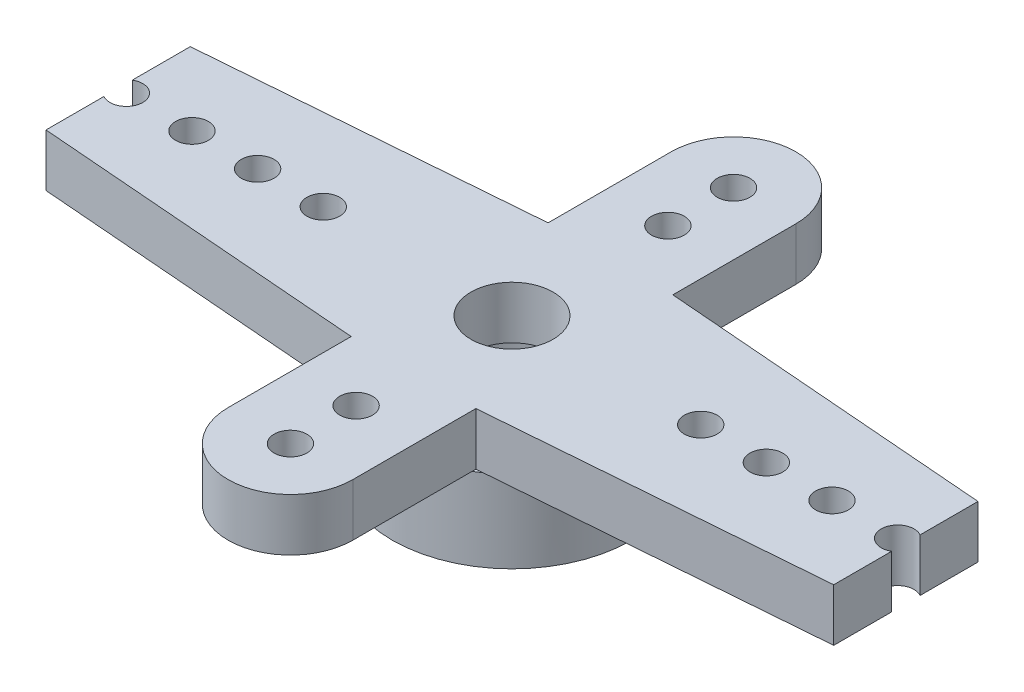
from build123d import *

# Parameters (mm, degrees)
SKETCH1_R           = 3.65
SKETCH1_R_2         = 2.5
BOSS_EXTRUDE1_DEPTH = 2.5
SKETCH2_R           = 1.25
BOSS_EXTRUDE2_DEPTH = 1.6
CUT_EXTRUDE1_REACH  = 6.1
SKETCH3_R           = 0.5
SKETCH4_W           = 8.285333373
SKETCH4_H           = 11.992925475
CUT_EXTRUDE2_DEPTH  = 5.1


with BuildPart() as part:
    # Sketch1 → Boss-Extrude1 (new body)
    with BuildSketch(Plane(origin=(0, 0, 0), x_dir=(1, 0, 0), z_dir=(0, 1, 0))):
        Circle(SKETCH1_R)
        Circle(SKETCH1_R_2, mode=Mode.SUBTRACT)
    extrude(amount=BOSS_EXTRUDE1_DEPTH)

    # Sketch2 → Boss-Extrude2 (add)
    with BuildSketch(Plane(origin=(0, 2.5, 0), x_dir=(1, 0, 0), z_dir=(0, 1, 0))):
        with BuildLine():
            Line((-1.9, 6.75), (-1.9, 3))
            Line((-1.9, 3), (-15.75, 1.9))
            ThreePointArc((-15.75, 1.9), (-17.65, 0), (-15.75, -1.9))
            Line((-15.75, -1.9), (-1.9, -3))
            Line((-1.9, -3), (-1.9, -6.75))
            ThreePointArc((-1.9, -6.75), (0, -8.65), (1.9, -6.75))
            Line((1.9, -6.75), (1.9, -3))
            Line((1.9, -3), (15.75, -1.9))
            ThreePointArc((15.75, -1.9), (17.65, 0), (15.75, 1.9))
            Line((15.75, 1.9), (1.9, 3))
            Line((1.9, 3), (1.9, 6.75))
            ThreePointArc((1.9, 6.75), (0, 8.65), (-1.9, 6.75))
        make_face()
        Circle(SKETCH2_R, mode=Mode.SUBTRACT)
    extrude(amount=BOSS_EXTRUDE2_DEPTH)

    # Sketch3 → Cut-Extrude1 (cut, up to next)
    with BuildSketch(Plane(origin=(0, 4.1, 0), x_dir=(1, 0, 0), z_dir=(0, 1, 0)), mode=Mode.PRIVATE) as cut_extrude1_sk1:
        with Locations((0, 6.75)):
            Circle(SKETCH3_R)
    cut_extrude1_tool1 = extrude(cut_extrude1_sk1.sketch, amount=-CUT_EXTRUDE1_REACH, mode=Mode.PRIVATE) & part.part
    add(cut_extrude1_tool1.solids().sort_by_distance((0, 4.1, -6.75))[0], mode=Mode.SUBTRACT)
    # Sketch3 → Cut-Extrude1 (cut, up to next)
    with BuildSketch(Plane(origin=(0, 4.1, 0), x_dir=(1, 0, 0), z_dir=(0, 1, 0)), mode=Mode.PRIVATE) as cut_extrude1_sk2:
        with Locations((0, 4.75)):
            Circle(SKETCH3_R)
    cut_extrude1_tool2 = extrude(cut_extrude1_sk2.sketch, amount=-CUT_EXTRUDE1_REACH, mode=Mode.PRIVATE) & part.part
    add(cut_extrude1_tool2.solids().sort_by_distance((0, 4.1, -4.75))[0], mode=Mode.SUBTRACT)
    # Sketch3 → Cut-Extrude1 (cut, up to next)
    with BuildSketch(Plane(origin=(0, 4.1, 0), x_dir=(1, 0, 0), z_dir=(0, 1, 0)), mode=Mode.PRIVATE) as cut_extrude1_sk3:
        with Locations((-15.75, 0)):
            Circle(SKETCH3_R)
    cut_extrude1_tool3 = extrude(cut_extrude1_sk3.sketch, amount=-CUT_EXTRUDE1_REACH, mode=Mode.PRIVATE) & part.part
    add(cut_extrude1_tool3.solids().sort_by_distance((-15.75, 4.1, 0))[0], mode=Mode.SUBTRACT)
    # Sketch3 → Cut-Extrude1 (cut, up to next)
    with BuildSketch(Plane(origin=(0, 4.1, 0), x_dir=(1, 0, 0), z_dir=(0, 1, 0)), mode=Mode.PRIVATE) as cut_extrude1_sk4:
        with Locations((-13.75, 0)):
            Circle(SKETCH3_R)
    cut_extrude1_tool4 = extrude(cut_extrude1_sk4.sketch, amount=-CUT_EXTRUDE1_REACH, mode=Mode.PRIVATE) & part.part
    add(cut_extrude1_tool4.solids().sort_by_distance((-13.75, 4.1, 0))[0], mode=Mode.SUBTRACT)
    # Sketch3 → Cut-Extrude1 (cut, up to next)
    with BuildSketch(Plane(origin=(0, 4.1, 0), x_dir=(1, 0, 0), z_dir=(0, 1, 0)), mode=Mode.PRIVATE) as cut_extrude1_sk5:
        with Locations((-11.75, 0)):
            Circle(SKETCH3_R)
    cut_extrude1_tool5 = extrude(cut_extrude1_sk5.sketch, amount=-CUT_EXTRUDE1_REACH, mode=Mode.PRIVATE) & part.part
    add(cut_extrude1_tool5.solids().sort_by_distance((-11.75, 4.1, 0))[0], mode=Mode.SUBTRACT)
    # Sketch3 → Cut-Extrude1 (cut, up to next)
    with BuildSketch(Plane(origin=(0, 4.1, 0), x_dir=(1, 0, 0), z_dir=(0, 1, 0)), mode=Mode.PRIVATE) as cut_extrude1_sk6:
        with Locations((-9.75, 0)):
            Circle(SKETCH3_R)
    cut_extrude1_tool6 = extrude(cut_extrude1_sk6.sketch, amount=-CUT_EXTRUDE1_REACH, mode=Mode.PRIVATE) & part.part
    add(cut_extrude1_tool6.solids().sort_by_distance((-9.75, 4.1, 0))[0], mode=Mode.SUBTRACT)
    # Sketch3 → Cut-Extrude1 (cut, up to next)
    with BuildSketch(Plane(origin=(0, 4.1, 0), x_dir=(1, 0, 0), z_dir=(0, 1, 0)), mode=Mode.PRIVATE) as cut_extrude1_sk7:
        with Locations((-7.75, 0)):
            Circle(SKETCH3_R)
    cut_extrude1_tool7 = extrude(cut_extrude1_sk7.sketch, amount=-CUT_EXTRUDE1_REACH, mode=Mode.PRIVATE) & part.part
    add(cut_extrude1_tool7.solids().sort_by_distance((-7.75, 4.1, 0))[0], mode=Mode.SUBTRACT)
    # Sketch3 → Cut-Extrude1 (cut, up to next)
    with BuildSketch(Plane(origin=(0, 4.1, 0), x_dir=(1, 0, 0), z_dir=(0, 1, 0)), mode=Mode.PRIVATE) as cut_extrude1_sk8:
        with Locations((-5.75, 0)):
            Circle(SKETCH3_R)
    cut_extrude1_tool8 = extrude(cut_extrude1_sk8.sketch, amount=-CUT_EXTRUDE1_REACH, mode=Mode.PRIVATE) & part.part
    add(cut_extrude1_tool8.solids().sort_by_distance((-5.75, 4.1, 0))[0], mode=Mode.SUBTRACT)
    # Sketch3 → Cut-Extrude1 (cut, up to next)
    with BuildSketch(Plane(origin=(0, 4.1, 0), x_dir=(1, 0, 0), z_dir=(0, 1, 0)), mode=Mode.PRIVATE) as cut_extrude1_sk9:
        with Locations((5.75, 0)):
            Circle(SKETCH3_R)
    cut_extrude1_tool9 = extrude(cut_extrude1_sk9.sketch, amount=-CUT_EXTRUDE1_REACH, mode=Mode.PRIVATE) & part.part
    add(cut_extrude1_tool9.solids().sort_by_distance((5.75, 4.1, 0))[0], mode=Mode.SUBTRACT)
    # Sketch3 → Cut-Extrude1 (cut, up to next)
    with BuildSketch(Plane(origin=(0, 4.1, 0), x_dir=(1, 0, 0), z_dir=(0, 1, 0)), mode=Mode.PRIVATE) as cut_extrude1_sk10:
        with Locations((7.75, 0)):
            Circle(SKETCH3_R)
    cut_extrude1_tool10 = extrude(cut_extrude1_sk10.sketch, amount=-CUT_EXTRUDE1_REACH, mode=Mode.PRIVATE) & part.part
    add(cut_extrude1_tool10.solids().sort_by_distance((7.75, 4.1, 0))[0], mode=Mode.SUBTRACT)
    # Sketch3 → Cut-Extrude1 (cut, up to next)
    with BuildSketch(Plane(origin=(0, 4.1, 0), x_dir=(1, 0, 0), z_dir=(0, 1, 0)), mode=Mode.PRIVATE) as cut_extrude1_sk11:
        with Locations((9.75, 0)):
            Circle(SKETCH3_R)
    cut_extrude1_tool11 = extrude(cut_extrude1_sk11.sketch, amount=-CUT_EXTRUDE1_REACH, mode=Mode.PRIVATE) & part.part
    add(cut_extrude1_tool11.solids().sort_by_distance((9.75, 4.1, 0))[0], mode=Mode.SUBTRACT)
    # Sketch3 → Cut-Extrude1 (cut, up to next)
    with BuildSketch(Plane(origin=(0, 4.1, 0), x_dir=(1, 0, 0), z_dir=(0, 1, 0)), mode=Mode.PRIVATE) as cut_extrude1_sk12:
        with Locations((11.75, 0)):
            Circle(SKETCH3_R)
    cut_extrude1_tool12 = extrude(cut_extrude1_sk12.sketch, amount=-CUT_EXTRUDE1_REACH, mode=Mode.PRIVATE) & part.part
    add(cut_extrude1_tool12.solids().sort_by_distance((11.75, 4.1, 0))[0], mode=Mode.SUBTRACT)
    # Sketch3 → Cut-Extrude1 (cut, up to next)
    with BuildSketch(Plane(origin=(0, 4.1, 0), x_dir=(1, 0, 0), z_dir=(0, 1, 0)), mode=Mode.PRIVATE) as cut_extrude1_sk13:
        with Locations((13.75, 0)):
            Circle(SKETCH3_R)
    cut_extrude1_tool13 = extrude(cut_extrude1_sk13.sketch, amount=-CUT_EXTRUDE1_REACH, mode=Mode.PRIVATE) & part.part
    add(cut_extrude1_tool13.solids().sort_by_distance((13.75, 4.1, 0))[0], mode=Mode.SUBTRACT)
    # Sketch3 → Cut-Extrude1 (cut, up to next)
    with BuildSketch(Plane(origin=(0, 4.1, 0), x_dir=(1, 0, 0), z_dir=(0, 1, 0)), mode=Mode.PRIVATE) as cut_extrude1_sk14:
        with Locations((15.75, 0)):
            Circle(SKETCH3_R)
    cut_extrude1_tool14 = extrude(cut_extrude1_sk14.sketch, amount=-CUT_EXTRUDE1_REACH, mode=Mode.PRIVATE) & part.part
    add(cut_extrude1_tool14.solids().sort_by_distance((15.75, 4.1, 0))[0], mode=Mode.SUBTRACT)
    # Sketch3 → Cut-Extrude1 (cut, up to next)
    with BuildSketch(Plane(origin=(0, 4.1, 0), x_dir=(1, 0, 0), z_dir=(0, 1, 0)), mode=Mode.PRIVATE) as cut_extrude1_sk15:
        with Locations((0, -4.75)):
            Circle(SKETCH3_R)
    cut_extrude1_tool15 = extrude(cut_extrude1_sk15.sketch, amount=-CUT_EXTRUDE1_REACH, mode=Mode.PRIVATE) & part.part
    add(cut_extrude1_tool15.solids().sort_by_distance((0, 4.1, 4.75))[0], mode=Mode.SUBTRACT)
    # Sketch3 → Cut-Extrude1 (cut, up to next)
    with BuildSketch(Plane(origin=(0, 4.1, 0), x_dir=(1, 0, 0), z_dir=(0, 1, 0)), mode=Mode.PRIVATE) as cut_extrude1_sk16:
        with Locations((0, -6.75)):
            Circle(SKETCH3_R)
    cut_extrude1_tool16 = extrude(cut_extrude1_sk16.sketch, amount=-CUT_EXTRUDE1_REACH, mode=Mode.PRIVATE) & part.part
    add(cut_extrude1_tool16.solids().sort_by_distance((0, 4.1, 6.75))[0], mode=Mode.SUBTRACT)

    # Sketch4 → Cut-Extrude2 (cut, through all)
    with BuildSketch(Plane(origin=(0, 4.1, 0), x_dir=(1, 0, 0), z_dir=(0, 1, 0))):
        with Locations((-16.142666687, 0.926898026)):
            Rectangle(SKETCH4_W, SKETCH4_H)
        with Locations((16.142666687, 0.926898026)):
            Rectangle(SKETCH4_W, SKETCH4_H)
    extrude(amount=-CUT_EXTRUDE2_DEPTH, mode=Mode.SUBTRACT)


solid = part.part
